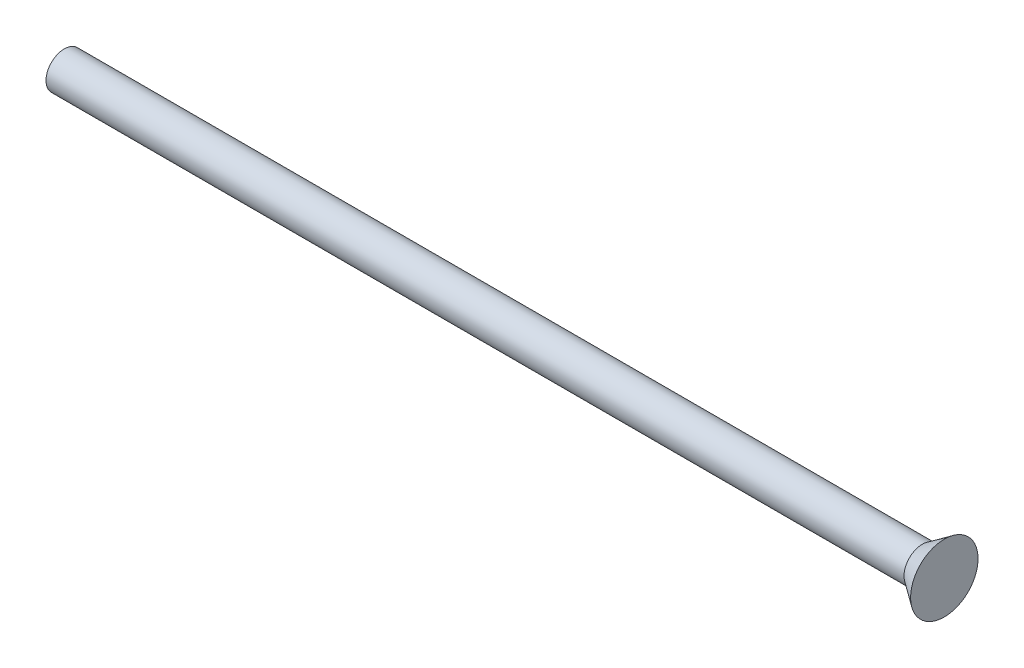
from build123d import *


with BuildPart() as part:
    # 草图1 → 旋转1 (revolve)
    with BuildSketch(Plane.XY):
        Polygon((-50, 0), (-50, 1.25), (8.5, 1.25), (10, 2.3), (10, 0), align=None)
    revolve(axis=Axis((-53.844089168, 0, 0), (1, 0, 0)))


solid = part.part
